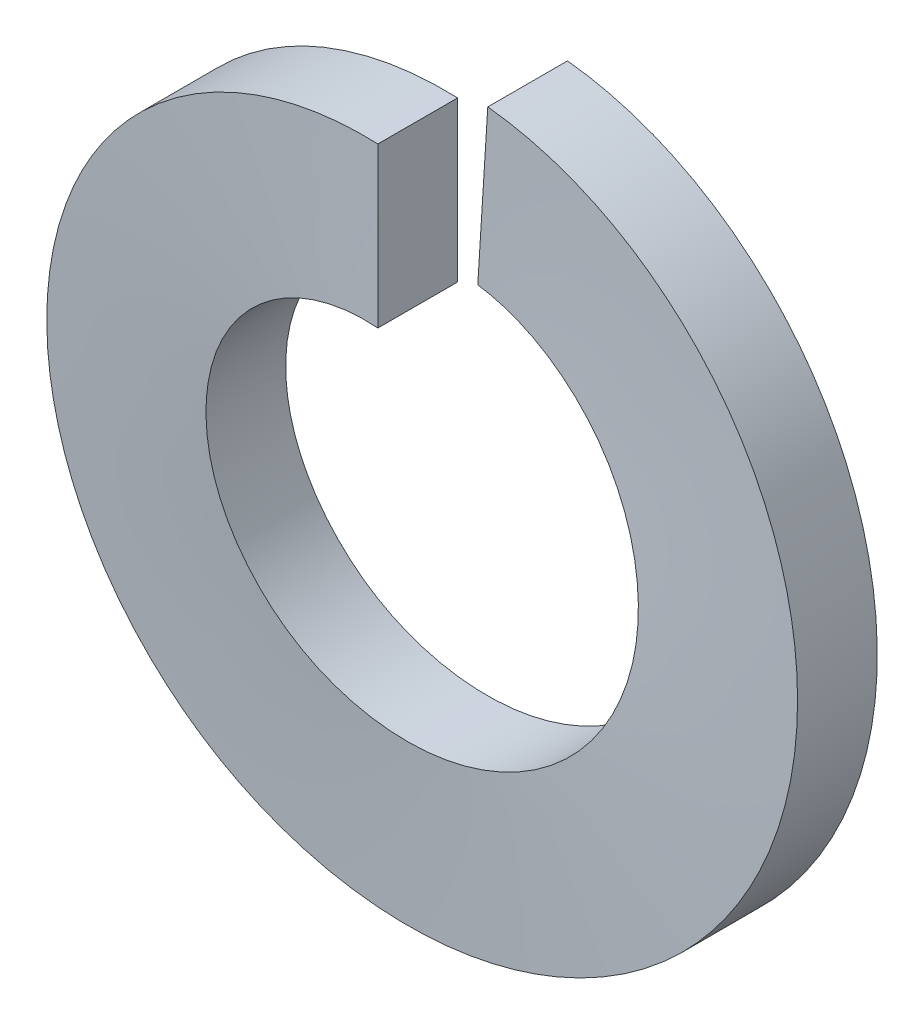
from build123d import *

# Parameters (mm, degrees)
SWEEP1_PITCH       = 0.777777778
SWEEP1_HEIGHT      = 0.77
SWEEP1_RADIUS      = 3.1
SWEEP1_START_ANGLE = 90
SKETCH2_W          = 0.7
SKETCH2_H          = 1.4


with BuildPart() as part:
    # Sweep1: sweep along a helix
    with BuildLine() as sweep1_path:
        add(Helix(SWEEP1_PITCH, SWEEP1_HEIGHT, SWEEP1_RADIUS, center=(0, 0, 0), direction=(0, 0, -1), lefthand=True, mode=Mode.PRIVATE).rotate(Axis((0, 0, 0), (0, 0, -1)), SWEEP1_START_ANGLE))
    # Sketch2 → Sweep1 (sweep)
    with BuildSketch(Plane(origin=(0, 0, 0), x_dir=(0, 0, -1), z_dir=(1, 0, 0))):
        with Locations((-0.35, 2.4)):
            Rectangle(SKETCH2_W, SKETCH2_H)
    sweep(path=sweep1_path.line, is_frenet=True)


solid = part.part
